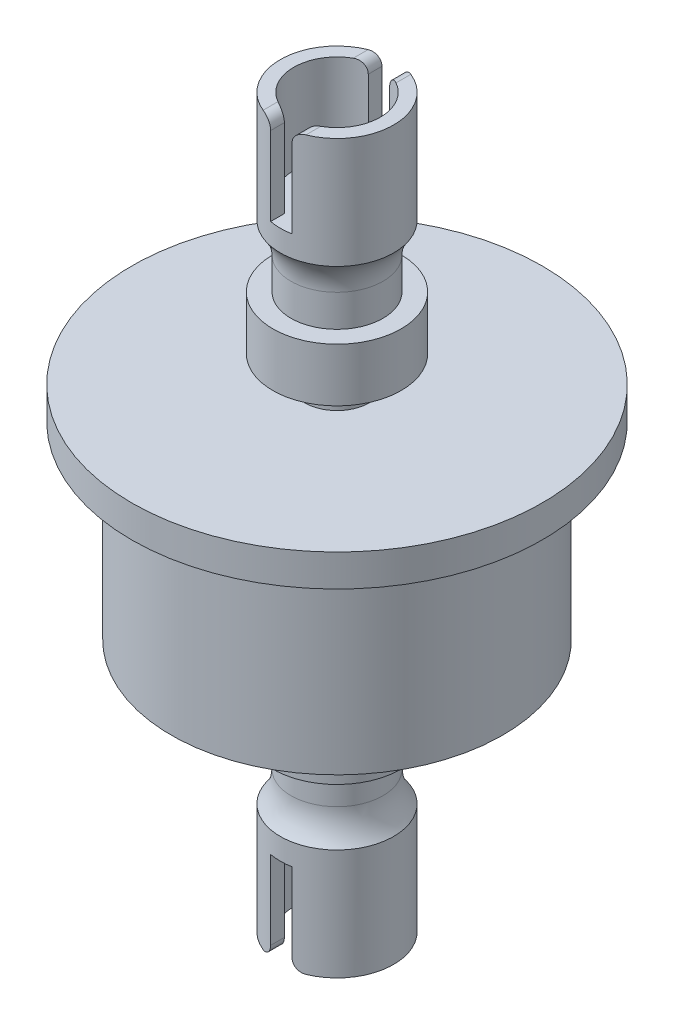
from build123d import *

# Parameters (mm, degrees)
CUT_EXTRUDE1_DEPTH      = 20.2
CUT_EXTRUDE1_DEPTH_BACK = 20.2
SKETCH3_R               = 4.05
CUT_EXTRUDE2_DEPTH      = 8.366667
SKETCH4_R               = 4.05
CUT_EXTRUDE3_DEPTH      = 8.366667


with BuildPart() as part:
    # Sketch1 → Revolve1 (revolve)
    with BuildSketch(Plane.XY):
        with BuildLine():
            Line((-1, 8.366666667), (0, 8.366666667))
            Line((0, 8.366666667), (0, 59.633333333))
            Line((0, 59.633333333), (-1, 59.633333333))
            Line((-1, 59.633333333), (-1, 67))
            ThreePointArc((-1, 67), (-1.292893219, 67.707106781), (-2, 68))
            Line((-2, 68), (-5.3, 68))
            Line((-5.3, 68), (-5.3, 57.633333333))
            ThreePointArc((-5.3, 57.633333333), (-4.557500751, 56.319940208), (-4.3, 54.833333333))
            Line((-4.3, 54.833333333), (-4.3, 51.833333333))
            Line((-4.3, 51.833333333), (-6, 51.833333333))
            Line((-6, 51.833333333), (-6, 46.833333333))
            Line((-6, 46.833333333), (-3, 46.833333333))
            Line((-3, 46.833333333), (-3, 44.333333333))
            Line((-3, 44.333333333), (-19.2, 44.333333333))
            Line((-19.2, 44.333333333), (-19.2, 41.333333333))
            Line((-19.2, 41.333333333), (-15.5, 41.333333333))
            Line((-15.5, 41.333333333), (-15.5, 23.666666667))
            Line((-15.5, 23.666666667), (-3, 23.666666667))
            Line((-3, 23.666666667), (-3, 21.166666667))
            Line((-3, 21.166666667), (-6, 21.166666667))
            Line((-6, 21.166666667), (-6, 16.166666667))
            Line((-6, 16.166666667), (-4.3, 16.166666667))
            Line((-4.3, 16.166666667), (-4.3, 13.166666667))
            ThreePointArc((-4.3, 13.166666667), (-4.557500751, 11.680059792), (-5.3, 10.366666667))
            Line((-5.3, 10.366666667), (-5.3, 0))
            Line((-5.3, 0), (-2, 0))
            ThreePointArc((-2, 0), (-1.292893219, 0.292893219), (-1, 1))
            Line((-1, 1), (-1, 8.366666667))
        make_face()
    revolve(axis=Axis((0, 0, 0), (0, 1, 0)))

    # Sketch2 → Cut-Extrude1 (cut, two sides)
    with BuildSketch(Plane.XY) as cut_extrude1_sk:
        with BuildLine():
            Line((1, 8.366666667), (0, 8.366666667))
            Line((0, 8.366666667), (0, 0))
            Line((0, 0), (2, 0))
            ThreePointArc((2, 0), (1.292893219, 0.292893219), (1, 1))
            Line((1, 1), (1, 8.366666667))
        make_face()
        with BuildLine():
            Line((-1, 8.366666667), (-1, 1))
            ThreePointArc((-1, 1), (-1.292893219, 0.292893219), (-2, 0))
            Line((-2, 0), (0, 0))
            Line((0, 0), (0, 8.366666667))
            Line((0, 8.366666667), (-1, 8.366666667))
        make_face()
        with BuildLine():
            Line((-1, 67), (-1, 59.633333333))
            Line((-1, 59.633333333), (1, 59.633333333))
            Line((1, 59.633333333), (1, 67))
            ThreePointArc((1, 67), (1.292893219, 67.707106781), (2, 68))
            Line((2, 68), (-2, 68))
            ThreePointArc((-2, 68), (-1.292893219, 67.707106781), (-1, 67))
        make_face()
    extrude(amount=CUT_EXTRUDE1_DEPTH, mode=Mode.SUBTRACT)
    extrude(cut_extrude1_sk.sketch, amount=-CUT_EXTRUDE1_DEPTH_BACK, mode=Mode.SUBTRACT)

    # Sketch3 → Cut-Extrude2 (cut)
    with BuildSketch(Plane(origin=(0, 68, 0), x_dir=(1, 0, 0), z_dir=(0, 1, 0))):
        Circle(SKETCH3_R)
    extrude(amount=-CUT_EXTRUDE2_DEPTH, mode=Mode.SUBTRACT)

    # Sketch4 → Cut-Extrude3 (cut)
    with BuildSketch(Plane.XZ):
        Circle(SKETCH4_R)
    extrude(amount=-CUT_EXTRUDE3_DEPTH, mode=Mode.SUBTRACT)


solid = part.part
